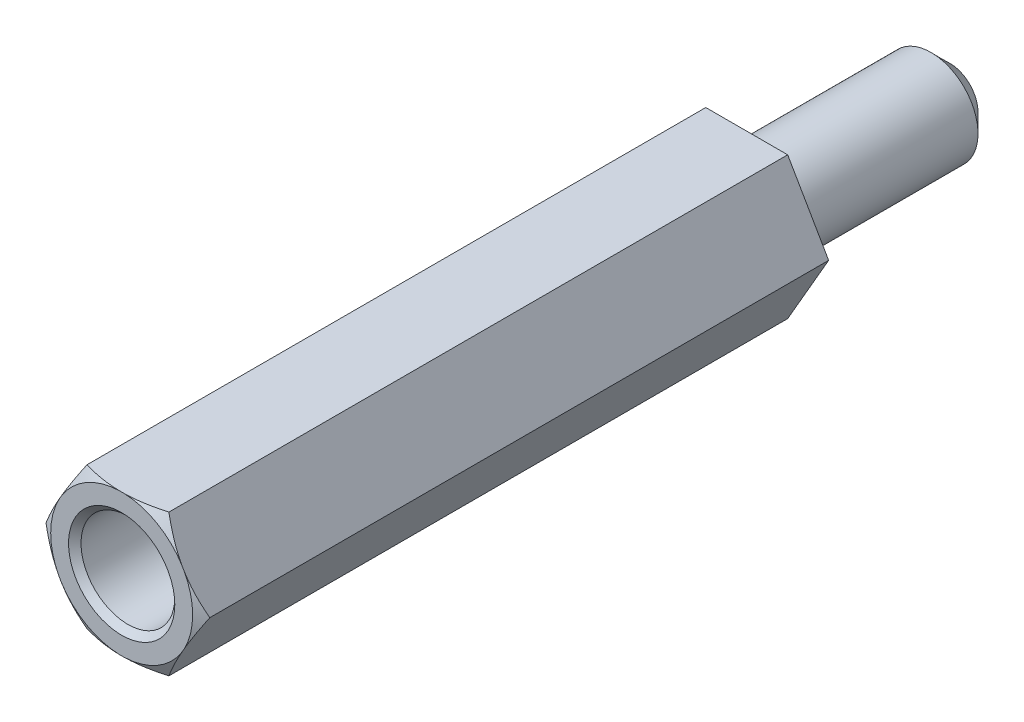
from build123d import *

# Parameters (mm, degrees)
BOSS_EXTRUDE1_DEPTH     = 20
SKETCH2_R               = 1.5
CUT_EXTRUDE1_DEPTH      = 1
CUT_EXTRUDE1_DEPTH_BACK = 12
CHAMFER1_SIZE           = 0.2
SKETCH4_R               = 1.5
BOSS_EXTRUDE2_DEPTH     = 6.5
CHAMFER2_SIZE           = 0.6


with BuildPart() as part:
    # Sketch1 → Boss-Extrude1 (new body)
    with BuildSketch(Plane.XY):
        Polygon((2.621170222, 0), (1.310585111, 2.27), (-1.310585111, 2.27), (-2.621170222, 0), (-1.310585111, -2.27), (1.310585111, -2.27), align=None)
    extrude(amount=BOSS_EXTRUDE1_DEPTH)

    # Sketch2 → Cut-Extrude1 (cut, two sides)
    with BuildSketch(Plane.XY.offset(20)) as cut_extrude1_sk:
        Circle(SKETCH2_R)
    extrude(amount=CUT_EXTRUDE1_DEPTH, mode=Mode.SUBTRACT)
    extrude(cut_extrude1_sk.sketch, amount=-CUT_EXTRUDE1_DEPTH_BACK, mode=Mode.SUBTRACT)

    # Sketch3 → Cut-Revolve1 (revolve, cut)
    with BuildSketch(Plane(origin=(0, 0, 0), x_dir=(1, 0, 0), z_dir=(0, 1, 0))):
        Polygon((-2.621170222, -20), (-2.271170222, -20), (-2.621170222, -19.8), align=None)
    revolve(axis=Axis((0, 0, 8), (0, 0, 1)), mode=Mode.SUBTRACT)

    # Chamfer1
    chamfer1_edges = [part.edges().sort_by_distance(p)[0] for p in [
        (-1.5, 0, 20),
    ]]
    chamfer(chamfer1_edges, length=CHAMFER1_SIZE)

    # Sketch4 → Boss-Extrude2 (add)
    with BuildSketch(Plane(origin=(0, 0, 0), x_dir=(-1, 0, 0), z_dir=(0, 0, -1))):
        Circle(SKETCH4_R)
    extrude(amount=BOSS_EXTRUDE2_DEPTH)

    # Chamfer2
    chamfer2_edges = [part.edges().sort_by_distance(p)[0] for p in [
        (1.5, 0, -6.5),
    ]]
    chamfer(chamfer2_edges, length=CHAMFER2_SIZE)


solid = part.part
